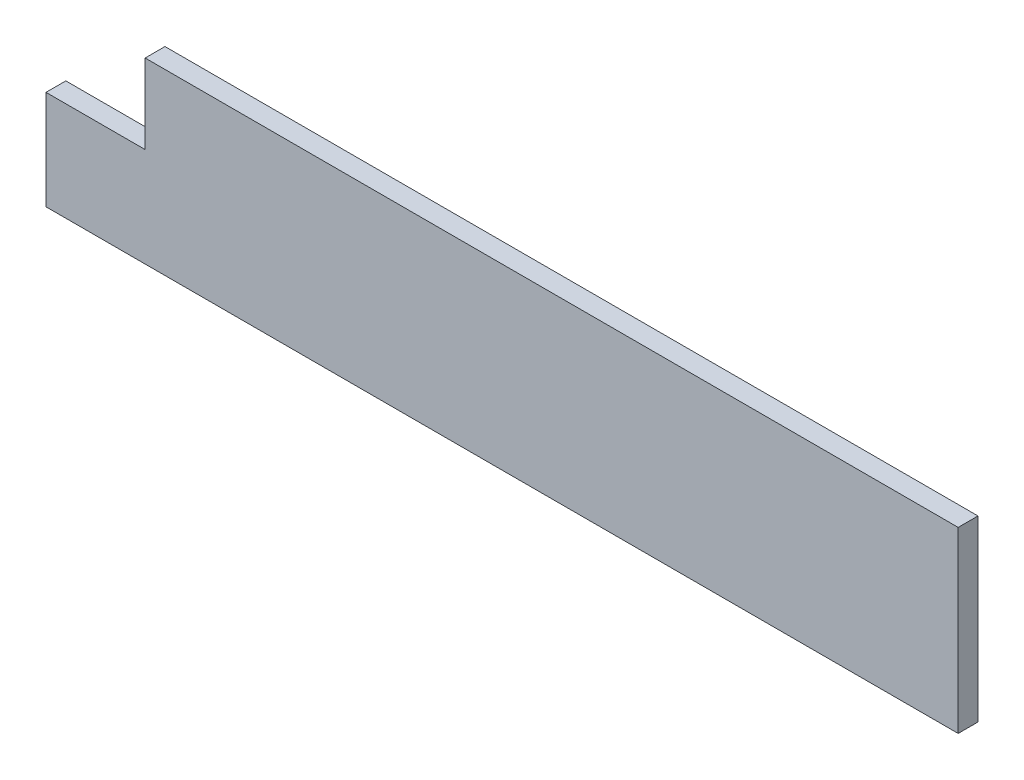
from build123d import *

# Parameters (mm, degrees)
SKETCH1_W               = 292.1
SKETCH1_H               = 57.15
BOSS_EXTRUDE1_DEPTH     = 6.35
SKETCH3_W               = 31.75
SKETCH3_H               = 25.4
CUT_EXTRUDE2_DEPTH      = 1
CUT_EXTRUDE2_DEPTH_BACK = 7.35


with BuildPart() as part:
    # Sketch1 → Boss-Extrude1 (new body)
    with BuildSketch(Plane.XY):
        with Locations((146.05, 28.575)):
            Rectangle(SKETCH1_W, SKETCH1_H)
    extrude(amount=BOSS_EXTRUDE1_DEPTH)

    # Sketch3 → Cut-Extrude2 (cut, two sides)
    with BuildSketch(Plane.XY.offset(6.35)) as cut_extrude2_sk:
        with Locations((15.875, 44.45)):
            Rectangle(SKETCH3_W, SKETCH3_H)
    extrude(amount=CUT_EXTRUDE2_DEPTH, mode=Mode.SUBTRACT)
    extrude(cut_extrude2_sk.sketch, amount=-CUT_EXTRUDE2_DEPTH_BACK, mode=Mode.SUBTRACT)


solid = part.part
